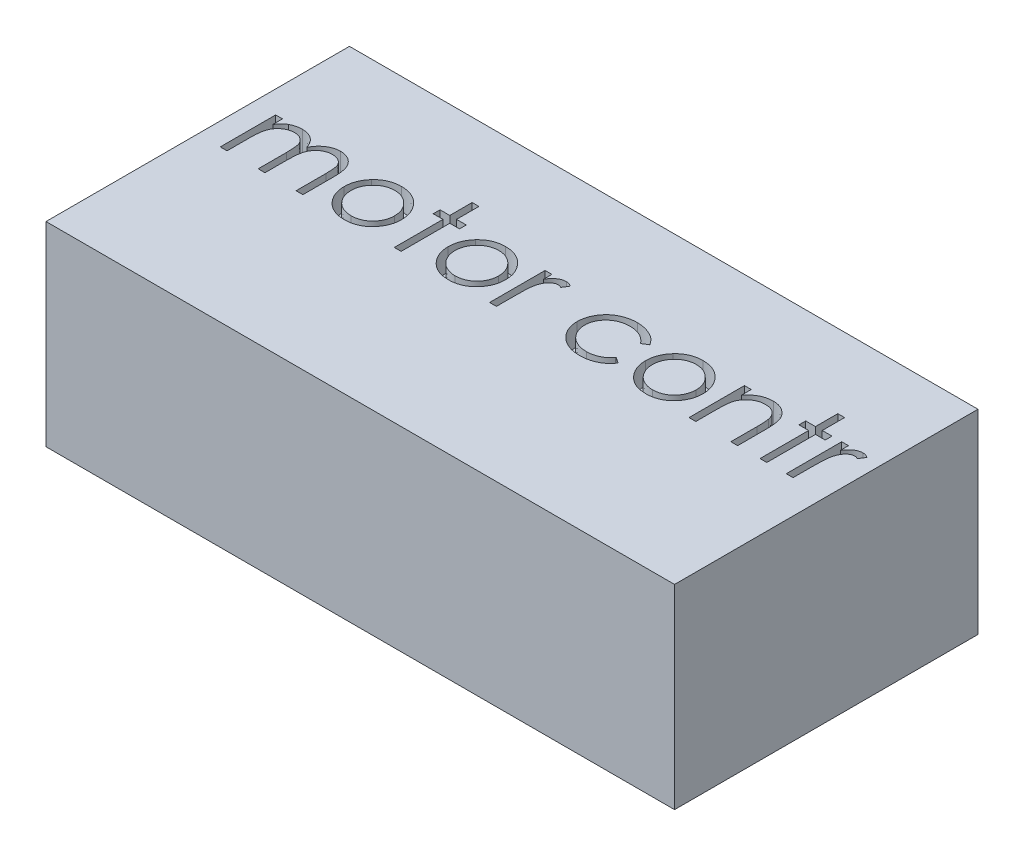
from build123d import *

# Parameters (mm, degrees)
SKETCH1_W           = 29
SKETCH1_H           = 14
BOSS_EXTRUDE1_DEPTH = 9
CUT_EXTRUDE1_DEPTH  = 1


with BuildPart() as part:
    # Sketch1 → Boss-Extrude1 (new body)
    with BuildSketch(Plane(origin=(0, 0, 0), x_dir=(1, 0, 0), z_dir=(0, 1, 0))):
        Rectangle(SKETCH1_W, SKETCH1_H)
    extrude(amount=BOSS_EXTRUDE1_DEPTH)

    # Sketch2 → Cut-Extrude1 (cut)
    with BuildSketch(Plane(origin=(0, 9, 0), x_dir=(1, 0, 0), z_dir=(0, 1, 0))):
        with BuildLine():
            Line((-13.461538462, 2.557692308), (-13.147435897, 2.557692308))
            Line((-13.147435897, 2.557692308), (-13.147435897, 2.11318109))
            add(Edge.make_bspline(
                [(-13.147435897, 2.11318109), (-13.119151948, 2.152068691), (-13.064957188, 2.226581065), (-12.976091535, 2.324771349), (-12.887315423, 2.408099503), (-12.823382041, 2.451842375), (-12.792668269, 2.472856571)],
                knots=[0, 0, 0, 0, 0.000144152, 0.000276209, 0.000396804, 0.000508302, 0.000508302, 0.000508302, 0.000508302], degree=3))
            add(Edge.make_bspline(
                [(-12.792668269, 2.472856571), (-12.750803607, 2.492861936), (-12.667805707, 2.532523149), (-12.536386482, 2.572756708), (-12.401911813, 2.597481809), (-12.311103599, 2.600863183), (-12.265424679, 2.602564103)],
                knots=[0, 0, 0, 0, 0.000139031, 0.000275633, 0.000410962, 0.000547939, 0.000547939, 0.000547939, 0.000547939], degree=3))
            add(Edge.make_bspline(
                [(-12.265424679, 2.602564103), (-12.234531683, 2.601518812), (-12.173396104, 2.599450238), (-12.082812014, 2.585990202), (-11.994953402, 2.562724029), (-11.910339373, 2.530316705), (-11.830618693, 2.491070018), (-11.757529496, 2.445020311), (-11.691905287, 2.393323235), (-11.633779236, 2.333644302), (-11.581510211, 2.264307704), (-11.533431364, 2.183443455), (-11.489006152, 2.089235794), (-11.464384843, 2.020869253), (-11.451422276, 1.984875801)],
                knots=[0, 0, 0, 0, 9.2678e-05, 0.000183405, 0.000274048, 0.000364807, 0.000454797, 0.00054019, 0.000623517, 0.000704829, 0.000789387, 0.000883415, 0.000986597, 0.001101318, 0.001101318, 0.001101318, 0.001101318], degree=3))
            add(Edge.make_bspline(
                [(-11.451422276, 1.984875801), (-11.437711024, 2.009600221), (-11.410729207, 2.058254406), (-11.36542357, 2.127112668), (-11.317955774, 2.19151946), (-11.267921281, 2.251525884), (-11.215496694, 2.306835614), (-11.160435293, 2.357631516), (-11.103050512, 2.40413173), (-11.023258272, 2.458454889), (-10.919445665, 2.516156071), (-10.78855755, 2.566184515), (-10.652407378, 2.597100643), (-10.55998968, 2.600730916), (-10.513321314, 2.602564103)],
                knots=[0, 0, 0, 0, 8.4789e-05, 0.000166854, 0.000247064, 0.000324714, 0.000401089, 0.000475513, 0.000549314, 0.000622436, 0.0007649, 0.000904487, 0.001041601, 0.001181469, 0.001181469, 0.001181469, 0.001181469], degree=3))
            add(Edge.make_bspline(
                [(-10.513321314, 2.602564103), (-10.470439851, 2.600946882), (-10.386516665, 2.597781823), (-10.264339399, 2.57292835), (-10.150397594, 2.530250703), (-10.044920518, 2.472017066), (-9.949760704, 2.398837883), (-9.867044395, 2.311769046), (-9.797274032, 2.211426423), (-9.751695392, 2.117034434), (-9.720780128, 2.033699101), (-9.701718894, 1.96269281), (-9.684879199, 1.884541257), (-9.670897953, 1.799150995), (-9.660679401, 1.706220387), (-9.653108686, 1.605901511), (-9.647984612, 1.498116399), (-9.64762254, 1.423750899), (-9.647435897, 1.385416667)],
                knots=[0, 0, 0, 0, 0.000128581, 0.000251645, 0.00037211, 0.000492305, 0.000611786, 0.000730807, 0.000851198, 0.000976936, 0.001044145, 0.001117629, 0.001197252, 0.00128393, 0.001377074, 0.001477631, 0.001585715, 0.001700707, 0.001700707, 0.001700707, 0.001700707], degree=3))
            Line((-9.647435897, 1.385416667), (-9.647435897, 0))
            Line((-9.647435897, 0), (-9.961538462, 0))
            Line((-9.961538462, 0), (-9.961538462, 1.38681891))
            add(Edge.make_bspline(
                [(-9.961538462, 1.38681891), (-9.961616345, 1.419539484), (-9.961766024, 1.482423451), (-9.964459655, 1.572675902), (-9.969534969, 1.654944259), (-9.975469608, 1.729116348), (-9.983713418, 1.795365136), (-9.994359349, 1.853557555), (-10.005637029, 1.904151366), (-10.02437302, 1.960237414), (-10.054320912, 2.022107624), (-10.099938392, 2.0888312), (-10.157408498, 2.146912), (-10.223768655, 2.197330317), (-10.299317099, 2.238323958), (-10.382581823, 2.267599968), (-10.473045874, 2.285722846), (-10.535668663, 2.287528862), (-10.568008814, 2.288461538)],
                knots=[0, 0, 0, 0, 9.816e-05, 0.000188648, 0.000270826, 0.000345412, 0.000411852, 0.000470988, 0.000522857, 0.0005672, 0.000648106, 0.000728233, 0.000808554, 0.000892128, 0.000977461, 0.001065278, 0.001156029, 0.001252946, 0.001252946, 0.001252946, 0.001252946], degree=3))
            add(Edge.make_bspline(
                [(-10.568008814, 2.288461538), (-10.607678768, 2.287045381), (-10.68608168, 2.284246516), (-10.800527166, 2.255672643), (-10.910498182, 2.212592392), (-11.012713315, 2.150159935), (-11.106741106, 2.075351571), (-11.187640684, 1.986401975), (-11.254472869, 1.885772048), (-11.299726845, 1.792625346), (-11.328316147, 1.708955902), (-11.347193062, 1.63585853), (-11.361876454, 1.552776962), (-11.375646983, 1.460269472), (-11.384634711, 1.357699291), (-11.392803083, 1.24554089), (-11.396623946, 1.123456931), (-11.397158405, 1.038830242), (-11.397435897, 0.994891827)],
                knots=[0, 0, 0, 0, 0.000118788, 0.00023477, 0.000351815, 0.000471937, 0.000592603, 0.000711217, 0.000831002, 0.000953929, 0.001020668, 0.001096002, 0.00118016, 0.001273662, 0.001376495, 0.001488939, 0.001611007, 0.001742825, 0.001742825, 0.001742825, 0.001742825], degree=3))
            Line((-11.397435897, 0.994891827), (-11.397435897, 0))
            Line((-11.397435897, 0), (-11.711538462, 0))
            Line((-11.711538462, 0), (-11.711538462, 1.300580929))
            add(Edge.make_bspline(
                [(-11.711538462, 1.300580929), (-11.711617893, 1.337274248), (-11.71177071, 1.407868505), (-11.714447027, 1.509102181), (-11.719533649, 1.601183261), (-11.725414197, 1.684004725), (-11.733874376, 1.757416053), (-11.743484138, 1.821810811), (-11.754832748, 1.877027563), (-11.773622633, 1.937590947), (-11.802337101, 2.00431187), (-11.848525363, 2.075452892), (-11.906132944, 2.137720989), (-11.973703819, 2.190879738), (-12.049709502, 2.234821219), (-12.133692902, 2.266480971), (-12.224897815, 2.28490526), (-12.287775521, 2.287253757), (-12.320112179, 2.288461538)],
                knots=[0, 0, 0, 0, 0.000110078, 0.00021178, 0.000303758, 0.00038673, 0.000460827, 0.00052538, 0.000582037, 0.000629718, 0.00071543, 0.000799052, 0.000882908, 0.000968755, 0.001056067, 0.001145266, 0.001236843, 0.001333803, 0.001333803, 0.001333803, 0.001333803], degree=3))
            add(Edge.make_bspline(
                [(-12.320112179, 2.288461538), (-12.358128391, 2.286931078), (-12.43389335, 2.283880926), (-12.54519532, 2.256426652), (-12.652681004, 2.213422577), (-12.754635702, 2.153762758), (-12.848309851, 2.07986368), (-12.930318118, 1.992948784), (-12.999260644, 1.89409975), (-13.044992458, 1.801935234), (-13.074490933, 1.720361959), (-13.094086267, 1.651011011), (-13.110925893, 1.574010763), (-13.123439915, 1.489123652), (-13.13552033, 1.396902558), (-13.141350639, 1.296888068), (-13.147022202, 1.18916598), (-13.147294616, 1.114793435), (-13.147435897, 1.076221955)],
                knots=[0, 0, 0, 0, 0.000113893, 0.000226985, 0.000341817, 0.000460265, 0.000580056, 0.000698595, 0.000817435, 0.000940348, 0.001005999, 0.001077458, 0.001156396, 0.001242271, 0.001334801, 0.001435306, 0.00154269, 0.001658383, 0.001658383, 0.001658383, 0.001658383], degree=3))
            Line((-13.147435897, 1.076221955), (-13.147435897, 0))
            Line((-13.147435897, 0), (-13.461538462, 0))
            Line((-13.461538462, 0), (-13.461538462, 2.557692308))
        make_face()
        with BuildLine():
            add(Edge.make_bspline(
                [(-7.694110577, 2.602564103), (-7.646119304, 2.601542211), (-7.552020147, 2.599538533), (-7.414212261, 2.578123567), (-7.282667125, 2.545376203), (-7.156880933, 2.500104641), (-7.038464637, 2.43942269), (-6.925693393, 2.367013399), (-6.818876384, 2.281230805), (-6.754853355, 2.214872737), (-6.722355769, 2.181189904)],
                knots=[0, 0, 0, 0, 0.000143868, 0.000282091, 0.000417278, 0.000550139, 0.000682145, 0.000815559, 0.000951665, 0.001091969, 0.001091969, 0.001091969, 0.001091969], degree=3))
            add(Edge.make_bspline(
                [(-6.722355769, 2.181189904), (-6.694373815, 2.148975918), (-6.638951435, 2.085171376), (-6.567885716, 1.981715763), (-6.506664156, 1.874575662), (-6.457601195, 1.762328336), (-6.418916171, 1.645953664), (-6.391450475, 1.525051653), (-6.37511354, 1.399889306), (-6.372910573, 1.314885468), (-6.371794872, 1.271834936)],
                knots=[0, 0, 0, 0, 0.000127922, 0.000253368, 0.000375813, 0.000497617, 0.000620225, 0.000743195, 0.000869033, 0.000998161, 0.000998161, 0.000998161, 0.000998161], degree=3))
            add(Edge.make_bspline(
                [(-6.371794872, 1.271834936), (-6.372776209, 1.228534878), (-6.374715377, 1.142971945), (-6.393058994, 1.016952579), (-6.42159008, 0.894757756), (-6.462421918, 0.776899063), (-6.514780027, 0.663016235), (-6.578670715, 0.553606686), (-6.654542332, 0.448454553), (-6.740546329, 0.348452714), (-6.835598205, 0.2562865), (-6.938714353, 0.17595823), (-7.047868387, 0.107136706), (-7.16451174, 0.05170029), (-7.287579227, 0.00799059), (-7.417336295, -0.022709427), (-7.553581365, -0.04127111), (-7.646608587, -0.043654684), (-7.694110577, -0.044871795)],
                knots=[0, 0, 0, 0, 0.000129829, 0.000256548, 0.000381202, 0.000505812, 0.000630045, 0.000756669, 0.000885282, 0.001018518, 0.001151902, 0.001281775, 0.001409974, 0.001538236, 0.001668405, 0.001801048, 0.001937587, 0.002080055, 0.002080055, 0.002080055, 0.002080055], degree=3))
            add(Edge.make_bspline(
                [(-7.694110577, -0.044871795), (-7.741845296, -0.043650599), (-7.835336156, -0.041258824), (-7.972062138, -0.022781541), (-8.102051757, 0.007976441), (-8.225280356, 0.051843934), (-8.342425202, 0.107138478), (-8.452211699, 0.175750167), (-8.555411615, 0.256310322), (-8.650483599, 0.348446259), (-8.736482205, 0.448456216), (-8.812355213, 0.553606254), (-8.876245539, 0.663016348), (-8.928603743, 0.776899033), (-8.969435556, 0.894757764), (-8.997966649, 1.016952577), (-9.016310263, 1.142971945), (-9.018249432, 1.228534878), (-9.019230769, 1.271834936)],
                knots=[0, 0, 0, 0, 0.000143168, 0.000280402, 0.000413045, 0.000543214, 0.000672108, 0.000800903, 0.000930775, 0.00106416, 0.001197395, 0.001326009, 0.001452632, 0.001576866, 0.001701476, 0.00182613, 0.001952849, 0.002082678, 0.002082678, 0.002082678, 0.002082678], degree=3))
            add(Edge.make_bspline(
                [(-9.019230769, 1.271834936), (-9.018107459, 1.314651482), (-9.015883497, 1.399420884), (-8.999562988, 1.524347945), (-8.972204432, 1.645045334), (-8.933473035, 1.76097081), (-8.883957845, 1.872726246), (-8.823596557, 1.980131077), (-8.751805924, 2.083118877), (-8.696603973, 2.146840957), (-8.668669872, 2.179086538)],
                knots=[0, 0, 0, 0, 0.000128428, 0.000254265, 0.000377235, 0.000499178, 0.000620341, 0.000743397, 0.000868267, 0.000996189, 0.000996189, 0.000996189, 0.000996189], degree=3))
            add(Edge.make_bspline(
                [(-8.668669872, 2.179086538), (-8.636221281, 2.213061478), (-8.572405417, 2.279879174), (-8.465056689, 2.365411698), (-8.352562868, 2.439327772), (-8.232837942, 2.498803987), (-8.107155084, 2.545642505), (-7.974935841, 2.57820802), (-7.836660326, 2.599461375), (-7.742100705, 2.601519553), (-7.694110577, 2.602564103)],
                knots=[0, 0, 0, 0, 0.000140798, 0.000276904, 0.000410699, 0.000543958, 0.000677061, 0.000812248, 0.000951858, 0.001095726, 0.001095726, 0.001095726, 0.001095726], degree=3))
        make_face()
        with BuildLine():
            add(Edge.make_bspline(
                [(-7.695512821, 2.288461538), (-7.729450432, 2.287496947), (-7.796449561, 2.285592664), (-7.895069145, 2.27110876), (-7.990009299, 2.248161255), (-8.081450143, 2.215557199), (-8.169083316, 2.1734583), (-8.252992718, 2.12174994), (-8.333425158, 2.061116984), (-8.408807221, 1.991654312), (-8.477989534, 1.915775317), (-8.53846751, 1.834926959), (-8.589892616, 1.750420612), (-8.632732775, 1.662168401), (-8.664639964, 1.569275987), (-8.687812986, 1.472795356), (-8.702283226, 1.37252994), (-8.704169605, 1.304368921), (-8.705128205, 1.269731571)],
                knots=[0, 0, 0, 0, 0.000101781, 0.000200935, 0.000298373, 0.000394396, 0.000491609, 0.000589491, 0.000689611, 0.000793323, 0.000896562, 0.000997243, 0.001095722, 0.001192936, 0.001290943, 0.001389744, 0.001490285, 0.001594167, 0.001594167, 0.001594167, 0.001594167], degree=3))
            add(Edge.make_bspline(
                [(-8.705128205, 1.269731571), (-8.703521381, 1.224979543), (-8.700332137, 1.136155138), (-8.674396901, 1.005344015), (-8.631010621, 0.879762163), (-8.572423341, 0.760145777), (-8.499017122, 0.649473499), (-8.412530056, 0.550802015), (-8.313890355, 0.465616203), (-8.204273855, 0.394935358), (-8.085919537, 0.338775602), (-7.960663216, 0.298976626), (-7.830022522, 0.273104934), (-7.740741791, 0.270533459), (-7.695512821, 0.269230769)],
                knots=[0, 0, 0, 0, 0.000134178, 0.000266319, 0.000398243, 0.00053182, 0.000664828, 0.000795487, 0.000924236, 0.001054533, 0.001185628, 0.001316003, 0.001448011, 0.001583547, 0.001583547, 0.001583547, 0.001583547], degree=3))
            add(Edge.make_bspline(
                [(-7.695512821, 0.269230769), (-7.650286452, 0.270541049), (-7.561010856, 0.273127506), (-7.430551679, 0.298846326), (-7.305637707, 0.338949987), (-7.187406319, 0.394872197), (-7.077839716, 0.465884611), (-6.978490595, 0.550320988), (-6.892741983, 0.64973484), (-6.819408379, 0.760292369), (-6.759861636, 0.879576721), (-6.716678434, 1.005367193), (-6.690680848, 1.136149235), (-6.687500019, 1.224977566), (-6.685897436, 1.269731571)],
                knots=[0, 0, 0, 0, 0.000135536, 0.000267545, 0.000397252, 0.000528347, 0.000658644, 0.000787925, 0.000918122, 0.00105113, 0.001185017, 0.001316942, 0.001449082, 0.00158326, 0.00158326, 0.00158326, 0.00158326], degree=3))
            add(Edge.make_bspline(
                [(-6.685897436, 1.269731571), (-6.686855706, 1.304369128), (-6.688741435, 1.372530554), (-6.703216399, 1.472793007), (-6.726371939, 1.569284604), (-6.758343556, 1.662136607), (-6.80099757, 1.750649112), (-6.853414363, 1.834678839), (-6.913645389, 1.916055385), (-6.98366251, 1.991409026), (-7.058965887, 2.061144062), (-7.139430926, 2.121773452), (-7.223215904, 2.173231047), (-7.310594487, 2.215917288), (-7.402047055, 2.247864628), (-7.496854184, 2.271241259), (-7.595052994, 2.285531456), (-7.661812037, 2.287478598), (-7.695512821, 2.288461538)],
                knots=[0, 0, 0, 0, 0.000103882, 0.000204424, 0.000303225, 0.000401232, 0.000498445, 0.000597291, 0.000697972, 0.000801684, 0.000905395, 0.001005516, 0.001103397, 0.001199979, 0.001296663, 0.00139342, 0.001492573, 0.001593654, 0.001593654, 0.001593654, 0.001593654], degree=3))
        make_face(mode=Mode.SUBTRACT)
        Polygon((-5.429487179, 3.58974359), (-5.115384615, 3.58974359), (-5.115384615, 2.557692308), (-4.666666667, 2.557692308), (-4.666666667, 2.243589744), (-5.115384615, 2.243589744), (-5.115384615, 0), (-5.429487179, 0), (-5.429487179, 2.243589744), (-5.878205128, 2.243589744), (-5.878205128, 2.557692308), (-5.429487179, 2.557692308), align=None)
        with BuildLine():
            add(Edge.make_bspline(
                [(-2.892828526, 2.602564103), (-2.844837253, 2.601542211), (-2.750738095, 2.599538533), (-2.612930209, 2.578123567), (-2.481385073, 2.545376203), (-2.355598881, 2.500104641), (-2.237182586, 2.43942269), (-2.124411342, 2.367013399), (-2.017594333, 2.281230805), (-1.953571304, 2.214872737), (-1.921073718, 2.181189904)],
                knots=[0, 0, 0, 0, 0.000143868, 0.000282091, 0.000417278, 0.000550139, 0.000682145, 0.000815559, 0.000951665, 0.001091969, 0.001091969, 0.001091969, 0.001091969], degree=3))
            add(Edge.make_bspline(
                [(-1.921073718, 2.181189904), (-1.893091764, 2.148975918), (-1.837669384, 2.085171376), (-1.766603665, 1.981715763), (-1.705382105, 1.874575662), (-1.656319144, 1.762328336), (-1.61763412, 1.645953664), (-1.590168424, 1.525051653), (-1.573831489, 1.399889306), (-1.571628522, 1.314885468), (-1.570512821, 1.271834936)],
                knots=[0, 0, 0, 0, 0.000127922, 0.000253368, 0.000375813, 0.000497617, 0.000620225, 0.000743195, 0.000869033, 0.000998161, 0.000998161, 0.000998161, 0.000998161], degree=3))
            add(Edge.make_bspline(
                [(-1.570512821, 1.271834936), (-1.571494158, 1.228534878), (-1.573433326, 1.142971945), (-1.591776943, 1.016952579), (-1.620308028, 0.894757756), (-1.661139867, 0.776899063), (-1.713497976, 0.663016235), (-1.777388663, 0.553606686), (-1.853260281, 0.448454553), (-1.939264277, 0.348452714), (-2.034316153, 0.2562865), (-2.137432302, 0.17595823), (-2.246586336, 0.107136706), (-2.363229689, 0.05170029), (-2.486297176, 0.00799059), (-2.616054244, -0.022709427), (-2.752299314, -0.04127111), (-2.845326535, -0.043654684), (-2.892828526, -0.044871795)],
                knots=[0, 0, 0, 0, 0.000129829, 0.000256548, 0.000381202, 0.000505812, 0.000630045, 0.000756669, 0.000885282, 0.001018518, 0.001151902, 0.001281775, 0.001409974, 0.001538236, 0.001668405, 0.001801048, 0.001937587, 0.002080055, 0.002080055, 0.002080055, 0.002080055], degree=3))
            add(Edge.make_bspline(
                [(-2.892828526, -0.044871795), (-2.940563245, -0.043650599), (-3.034054105, -0.041258824), (-3.170780087, -0.022781541), (-3.300769706, 0.007976441), (-3.423998304, 0.051843934), (-3.541143151, 0.107138478), (-3.650929648, 0.175750167), (-3.754129564, 0.256310322), (-3.849201548, 0.348446259), (-3.935200153, 0.448456216), (-4.011073162, 0.553606254), (-4.074963488, 0.663016348), (-4.127321692, 0.776899033), (-4.168153505, 0.894757764), (-4.196684597, 1.016952577), (-4.215028212, 1.142971945), (-4.216967381, 1.228534878), (-4.217948718, 1.271834936)],
                knots=[0, 0, 0, 0, 0.000143168, 0.000280402, 0.000413045, 0.000543214, 0.000672108, 0.000800903, 0.000930775, 0.00106416, 0.001197395, 0.001326009, 0.001452632, 0.001576866, 0.001701476, 0.00182613, 0.001952849, 0.002082678, 0.002082678, 0.002082678, 0.002082678], degree=3))
            add(Edge.make_bspline(
                [(-4.217948718, 1.271834936), (-4.216825408, 1.314651482), (-4.214601446, 1.399420884), (-4.198280937, 1.524347945), (-4.170922381, 1.645045334), (-4.132190984, 1.76097081), (-4.082675793, 1.872726246), (-4.022314505, 1.980131077), (-3.950523873, 2.083118877), (-3.895321921, 2.146840957), (-3.867387821, 2.179086538)],
                knots=[0, 0, 0, 0, 0.000128428, 0.000254265, 0.000377235, 0.000499178, 0.000620341, 0.000743397, 0.000868267, 0.000996189, 0.000996189, 0.000996189, 0.000996189], degree=3))
            add(Edge.make_bspline(
                [(-3.867387821, 2.179086538), (-3.834939229, 2.213061478), (-3.771123366, 2.279879174), (-3.663774638, 2.365411698), (-3.551280817, 2.439327772), (-3.431555891, 2.498803987), (-3.305873033, 2.545642505), (-3.17365379, 2.57820802), (-3.035378275, 2.599461375), (-2.940818654, 2.601519553), (-2.892828526, 2.602564103)],
                knots=[0, 0, 0, 0, 0.000140798, 0.000276904, 0.000410699, 0.000543958, 0.000677061, 0.000812248, 0.000951858, 0.001095726, 0.001095726, 0.001095726, 0.001095726], degree=3))
        make_face()
        with BuildLine():
            add(Edge.make_bspline(
                [(-2.894230769, 2.288461538), (-2.928168381, 2.287496947), (-2.995167509, 2.285592664), (-3.093787094, 2.27110876), (-3.188727248, 2.248161255), (-3.280168092, 2.215557199), (-3.367801264, 2.1734583), (-3.451710667, 2.12174994), (-3.532143107, 2.061116984), (-3.60752517, 1.991654312), (-3.676707482, 1.915775317), (-3.737185459, 1.834926959), (-3.788610565, 1.750420612), (-3.831450724, 1.662168401), (-3.863357912, 1.569275987), (-3.886530935, 1.472795356), (-3.901001175, 1.37252994), (-3.902887554, 1.304368921), (-3.903846154, 1.269731571)],
                knots=[0, 0, 0, 0, 0.000101781, 0.000200935, 0.000298373, 0.000394396, 0.000491609, 0.000589491, 0.000689611, 0.000793323, 0.000896562, 0.000997243, 0.001095722, 0.001192936, 0.001290943, 0.001389744, 0.001490285, 0.001594167, 0.001594167, 0.001594167, 0.001594167], degree=3))
            add(Edge.make_bspline(
                [(-3.903846154, 1.269731571), (-3.90223933, 1.224979543), (-3.899050086, 1.136155138), (-3.873114849, 1.005344015), (-3.829728569, 0.879762163), (-3.77114129, 0.760145777), (-3.697735071, 0.649473499), (-3.611248004, 0.550802015), (-3.512608304, 0.465616203), (-3.402991804, 0.394935358), (-3.284637486, 0.338775602), (-3.159381165, 0.298976626), (-3.028740471, 0.273104934), (-2.93945974, 0.270533459), (-2.894230769, 0.269230769)],
                knots=[0, 0, 0, 0, 0.000134178, 0.000266319, 0.000398243, 0.00053182, 0.000664828, 0.000795487, 0.000924236, 0.001054533, 0.001185628, 0.001316003, 0.001448011, 0.001583547, 0.001583547, 0.001583547, 0.001583547], degree=3))
            add(Edge.make_bspline(
                [(-2.894230769, 0.269230769), (-2.8490044, 0.270541049), (-2.759728804, 0.273127506), (-2.629269627, 0.298846326), (-2.504355656, 0.338949987), (-2.386124268, 0.394872197), (-2.276557665, 0.465884611), (-2.177208543, 0.550320988), (-2.091459932, 0.64973484), (-2.018126327, 0.760292369), (-1.958579585, 0.879576721), (-1.915396383, 1.005367193), (-1.889398797, 1.136149235), (-1.886217968, 1.224977566), (-1.884615385, 1.269731571)],
                knots=[0, 0, 0, 0, 0.000135536, 0.000267545, 0.000397252, 0.000528347, 0.000658644, 0.000787925, 0.000918122, 0.00105113, 0.001185017, 0.001316942, 0.001449082, 0.00158326, 0.00158326, 0.00158326, 0.00158326], degree=3))
            add(Edge.make_bspline(
                [(-1.884615385, 1.269731571), (-1.885573655, 1.304369128), (-1.887459384, 1.372530554), (-1.901934348, 1.472793007), (-1.925089888, 1.569284604), (-1.957061505, 1.662136607), (-1.999715519, 1.750649112), (-2.052132312, 1.834678839), (-2.112363337, 1.916055385), (-2.182380458, 1.991409026), (-2.257683836, 2.061144062), (-2.338148874, 2.121773452), (-2.421933853, 2.173231047), (-2.509312436, 2.215917288), (-2.600765003, 2.247864628), (-2.695572132, 2.271241259), (-2.793770942, 2.285531456), (-2.860529986, 2.287478598), (-2.894230769, 2.288461538)],
                knots=[0, 0, 0, 0, 0.000103882, 0.000204424, 0.000303225, 0.000401232, 0.000498445, 0.000597291, 0.000697972, 0.000801684, 0.000905395, 0.001005516, 0.001103397, 0.001199979, 0.001296663, 0.00139342, 0.001492573, 0.001593654, 0.001593654, 0.001593654, 0.001593654], degree=3))
        make_face(mode=Mode.SUBTRACT)
        with BuildLine():
            Line((-1.032051282, 2.557692308), (-0.717948718, 2.557692308))
            Line((-0.717948718, 2.557692308), (-0.717948718, 2.181189904))
            add(Edge.make_bspline(
                [(-0.717948718, 2.181189904), (-0.694759959, 2.216245732), (-0.650411638, 2.283289731), (-0.576698709, 2.371959032), (-0.501195378, 2.445374079), (-0.42354019, 2.503877598), (-0.34316209, 2.547690717), (-0.261825139, 2.579783752), (-0.178249669, 2.598761067), (-0.122087745, 2.601294726), (-0.093950321, 2.602564103)],
                knots=[0, 0, 0, 0, 0.000126023, 0.000241017, 0.000345147, 0.000441342, 0.00053171, 0.000618946, 0.000702978, 0.000787349, 0.000787349, 0.000787349, 0.000787349], degree=3))
            add(Edge.make_bspline(
                [(-0.093950321, 2.602564103), (-0.072123994, 2.601373576), (-0.027214909, 2.59892399), (0.040767681, 2.581713165), (0.110811133, 2.554235143), (0.15595352, 2.52839492), (0.179487179, 2.514923878)],
                knots=[0, 0, 0, 0, 6.5445e-05, 0.000134658, 0.00020926, 0.000290509, 0.000290509, 0.000290509, 0.000290509], degree=3))
            Line((0.179487179, 2.514923878), (0.007011218, 2.242888622))
            add(Edge.make_bspline(
                [(0.007011218, 2.242888622), (-0.008097803, 2.249628888), (-0.036777618, 2.262423203), (-0.078732184, 2.277565213), (-0.117413521, 2.286481129), (-0.142057079, 2.287831847), (-0.153545673, 2.288461538)],
                knots=[0, 0, 0, 0, 4.9621e-05, 9.4191e-05, 0.00013366, 0.000168129, 0.000168129, 0.000168129, 0.000168129], degree=3))
            add(Edge.make_bspline(
                [(-0.153545673, 2.288461538), (-0.178751407, 2.286781501), (-0.230163797, 2.283354712), (-0.305648296, 2.256415904), (-0.378895501, 2.212890664), (-0.437067164, 2.164619552), (-0.482109417, 2.118071755), (-0.514249642, 2.077423352), (-0.543732389, 2.031844721), (-0.57190261, 1.982115037), (-0.597568904, 1.927385191), (-0.621523573, 1.868201977), (-0.643182436, 1.804496849), (-0.65553268, 1.760114328), (-0.661858974, 1.737379808)],
                knots=[0, 0, 0, 0, 7.549e-05, 0.000153978, 0.000237553, 0.000330197, 0.000379784, 0.000431685, 0.000485357, 0.000542493, 0.000603021, 0.000666557, 0.00073396, 0.000804745, 0.000804745, 0.000804745, 0.000804745], degree=3))
            add(Edge.make_bspline(
                [(-0.661858974, 1.737379808), (-0.666591368, 1.717102634), (-0.677073259, 1.672190235), (-0.687264797, 1.596841711), (-0.697334315, 1.507818052), (-0.704430934, 1.404871459), (-0.711008976, 1.288259015), (-0.714719058, 1.15780307), (-0.717822199, 1.013369718), (-0.717905265, 0.912395365), (-0.717948718, 0.859575321)],
                knots=[0, 0, 0, 0, 6.2435e-05, 0.000138289, 0.000227871, 0.000331224, 0.000447781, 0.000578258, 0.000722716, 0.000881171, 0.000881171, 0.000881171, 0.000881171], degree=3))
            Line((-0.717948718, 0.859575321), (-0.717948718, 0))
            Line((-0.717948718, 0), (-1.032051282, 0))
            Line((-1.032051282, 0), (-1.032051282, 2.557692308))
        make_face()
        with BuildLine():
            Line((4.352564103, 2.003104968), (4.089643429, 1.83974359))
            add(Edge.make_bspline(
                [(4.089643429, 1.83974359), (4.060813564, 1.875571984), (4.004066869, 1.946094094), (3.905527633, 2.037104027), (3.800516218, 2.115271069), (3.687238171, 2.17897482), (3.565852371, 2.22819627), (3.436837519, 2.263026476), (3.300212014, 2.284730719), (3.206546815, 2.287197555), (3.158553686, 2.288461538)],
                knots=[0, 0, 0, 0, 0.0001378, 0.000271237, 0.000401088, 0.000529797, 0.000659994, 0.000793002, 0.000929944, 0.001073845, 0.001073845, 0.001073845, 0.001073845], degree=3))
            add(Edge.make_bspline(
                [(3.158553686, 2.288461538), (3.120194729, 2.287404696), (3.044647806, 2.285323274), (2.933741653, 2.272312781), (2.8280993, 2.248670773), (2.727058591, 2.217519816), (2.631338172, 2.175769526), (2.540687254, 2.12495977), (2.454301764, 2.06590973), (2.374685023, 1.997499184), (2.301856015, 1.923100516), (2.238757101, 1.843346821), (2.183820168, 1.76062693), (2.140714212, 1.672875188), (2.105439041, 1.582099134), (2.082232321, 1.486585279), (2.066767626, 1.387557271), (2.064998297, 1.320038931), (2.064102564, 1.285857372)],
                knots=[0, 0, 0, 0, 0.000115089, 0.000226664, 0.000334347, 0.000439455, 0.000543394, 0.000646972, 0.000750824, 0.000856758, 0.000961376, 0.00106266, 0.001161449, 0.00125865, 0.001355399, 0.001453007, 0.001552955, 0.001655437, 0.001655437, 0.001655437, 0.001655437], degree=3))
            add(Edge.make_bspline(
                [(2.064102564, 1.285857372), (2.065881816, 1.241088161), (2.069416347, 1.152152965), (2.097117807, 1.020874863), (2.142462214, 0.893951173), (2.204520065, 0.772283036), (2.282997199, 0.65968888), (2.375169762, 0.558705426), (2.481088846, 0.471289398), (2.599821176, 0.398816873), (2.72857892, 0.340555505), (2.865969024, 0.299048172), (3.010868805, 0.2739958), (3.110075552, 0.270839857), (3.160657051, 0.269230769)],
                knots=[0, 0, 0, 0, 0.000134224, 0.00026664, 0.000400581, 0.000537609, 0.000675117, 0.000811087, 0.000946551, 0.001085679, 0.001227203, 0.001369372, 0.001515181, 0.001666857, 0.001666857, 0.001666857, 0.001666857], degree=3))
            add(Edge.make_bspline(
                [(3.160657051, 0.269230769), (3.207012236, 0.270530266), (3.298112474, 0.273084123), (3.431279759, 0.294613087), (3.55805967, 0.32985672), (3.678447701, 0.37900437), (3.792223867, 0.442531886), (3.898653042, 0.520891057), (3.99985298, 0.611827657), (4.059349956, 0.682145629), (4.089643429, 0.717948718)],
                knots=[0, 0, 0, 0, 0.000138999, 0.00027317, 0.000403475, 0.000533023, 0.000662344, 0.000793326, 0.000928824, 0.001069379, 0.001069379, 0.001069379, 0.001069379], degree=3))
            Line((4.089643429, 0.717948718), (4.352564103, 0.545472756))
            add(Edge.make_bspline(
                [(4.352564103, 0.545472756), (4.3369764, 0.522582029), (4.305852733, 0.476876553), (4.253825108, 0.412432436), (4.197705276, 0.352110754), (4.137712179, 0.295992364), (4.07462917, 0.242734345), (4.00630126, 0.19488277), (3.934931649, 0.149747947), (3.859682491, 0.109135075), (3.781331793, 0.072628754), (3.699989803, 0.041237583), (3.61600999, 0.014267477), (3.529293614, -0.00716987), (3.439669716, -0.024280708), (3.347370082, -0.03563441), (3.2524265, -0.044109691), (3.188254349, -0.044615558), (3.155749199, -0.044871795)],
                knots=[0, 0, 0, 0, 8.3056e-05, 0.000165835, 0.000248187, 0.000330026, 0.000412165, 0.000495625, 0.000580051, 0.000665384, 0.00075196, 0.000839196, 0.00092678, 0.001016395, 0.001107013, 0.001200326, 0.001295291, 0.001392769, 0.001392769, 0.001392769, 0.001392769], degree=3))
            add(Edge.make_bspline(
                [(3.155749199, -0.044871795), (3.106138315, -0.043980515), (3.008900623, -0.0422336), (2.866578115, -0.023025125), (2.730564448, 0.005932491), (2.60090609, 0.047496225), (2.477582856, 0.101001001), (2.360709738, 0.166357915), (2.250673719, 0.244109705), (2.148562937, 0.332872475), (2.054781491, 0.429113115), (1.9742553, 0.532963033), (1.90441003, 0.640604081), (1.848322487, 0.754413607), (1.80367556, 0.87287898), (1.773170727, 0.99694922), (1.75344099, 1.125601474), (1.75115761, 1.213334356), (1.75, 1.2578125)],
                knots=[0, 0, 0, 0, 0.000148744, 0.000291539, 0.000430022, 0.000565498, 0.000699266, 0.000832672, 0.000966504, 0.001102706, 0.001238073, 0.00136893, 0.00149632, 0.001622368, 0.001748823, 0.001875338, 0.002005032, 0.002138395, 0.002138395, 0.002138395, 0.002138395], degree=3))
            add(Edge.make_bspline(
                [(1.75, 1.2578125), (1.750441016, 1.287990935), (1.75131827, 1.348020822), (1.761380198, 1.437115889), (1.774378671, 1.525024434), (1.796404408, 1.610632153), (1.821845039, 1.695237443), (1.854320571, 1.777820545), (1.892415966, 1.858765217), (1.935667913, 1.937862947), (1.984356659, 2.013812487), (2.038237892, 2.085566151), (2.095282228, 2.153985917), (2.15815834, 2.216709677), (2.224197994, 2.276245869), (2.29526957, 2.331003993), (2.370965421, 2.381144984), (2.450148744, 2.427595999), (2.532773455, 2.468955434), (2.618340126, 2.504588672), (2.706333155, 2.535041248), (2.796893299, 2.559150167), (2.889419472, 2.579367591), (2.98464081, 2.592085437), (3.082193032, 2.60107171), (3.148249055, 2.602062502), (3.181690705, 2.602564103)],
                knots=[0, 0, 0, 0, 9.0488e-05, 0.000179996, 0.000268751, 0.000356836, 0.000444879, 0.000533675, 0.000622751, 0.00071312, 0.000803944, 0.000893127, 0.000982181, 0.001070925, 0.00115931, 0.001248782, 0.001339788, 0.001431538, 0.001524036, 0.001616746, 0.001709427, 0.001803141, 0.001897749, 0.001993333, 0.002091151, 0.002191451, 0.002191451, 0.002191451, 0.002191451], degree=3))
            add(Edge.make_bspline(
                [(3.181690705, 2.602564103), (3.223570813, 2.601642212), (3.307121693, 2.599803037), (3.431062399, 2.584324385), (3.553177593, 2.560987969), (3.671324697, 2.526415139), (3.784071211, 2.484551483), (3.889606661, 2.437538769), (3.985446765, 2.382944165), (4.073374354, 2.323224051), (4.153553872, 2.255863145), (4.226808364, 2.180056188), (4.294640014, 2.096197709), (4.333096725, 2.034391978), (4.352564103, 2.003104968)],
                knots=[0, 0, 0, 0, 0.000125597, 0.000250566, 0.00037418, 0.000498223, 0.000619345, 0.000734815, 0.00084439, 0.000949794, 0.001053299, 0.001157917, 0.001265662, 0.001376119, 0.001376119, 0.001376119, 0.001376119], degree=3))
        make_face()
        with BuildLine():
            add(Edge.make_bspline(
                [(6.216145833, 2.602564103), (6.264137106, 2.601542211), (6.358236264, 2.599538533), (6.49604415, 2.578123567), (6.627589286, 2.545376203), (6.753375478, 2.500104641), (6.871791773, 2.43942269), (6.984563017, 2.367013399), (7.091380026, 2.281230805), (7.155403055, 2.214872737), (7.187900641, 2.181189904)],
                knots=[0, 0, 0, 0, 0.000143868, 0.000282091, 0.000417278, 0.000550139, 0.000682145, 0.000815559, 0.000951665, 0.001091969, 0.001091969, 0.001091969, 0.001091969], degree=3))
            add(Edge.make_bspline(
                [(7.187900641, 2.181189904), (7.215882595, 2.148975918), (7.271304975, 2.085171376), (7.342370694, 1.981715763), (7.403592254, 1.874575662), (7.452655215, 1.762328336), (7.491340239, 1.645953664), (7.518805935, 1.525051653), (7.53514287, 1.399889306), (7.537345837, 1.314885468), (7.538461538, 1.271834936)],
                knots=[0, 0, 0, 0, 0.000127922, 0.000253368, 0.000375813, 0.000497617, 0.000620225, 0.000743195, 0.000869033, 0.000998161, 0.000998161, 0.000998161, 0.000998161], degree=3))
            add(Edge.make_bspline(
                [(7.538461538, 1.271834936), (7.537480201, 1.228534878), (7.535541033, 1.142971945), (7.517197416, 1.016952579), (7.488666331, 0.894757756), (7.447834492, 0.776899063), (7.395476383, 0.663016235), (7.331585696, 0.553606686), (7.255714078, 0.448454553), (7.169710082, 0.348452714), (7.074658206, 0.2562865), (6.971542057, 0.17595823), (6.862388023, 0.107136706), (6.74574467, 0.05170029), (6.622677183, 0.00799059), (6.492920115, -0.022709427), (6.356675045, -0.04127111), (6.263647824, -0.043654684), (6.216145833, -0.044871795)],
                knots=[0, 0, 0, 0, 0.000129829, 0.000256548, 0.000381202, 0.000505812, 0.000630045, 0.000756669, 0.000885282, 0.001018518, 0.001151902, 0.001281775, 0.001409974, 0.001538236, 0.001668405, 0.001801048, 0.001937587, 0.002080055, 0.002080055, 0.002080055, 0.002080055], degree=3))
            add(Edge.make_bspline(
                [(6.216145833, -0.044871795), (6.168411114, -0.043650599), (6.074920254, -0.041258824), (5.938194272, -0.022781541), (5.808204653, 0.007976441), (5.684976055, 0.051843934), (5.567831208, 0.107138478), (5.458044711, 0.175750167), (5.354844795, 0.256310322), (5.259772811, 0.348446259), (5.173774206, 0.448456216), (5.097901197, 0.553606254), (5.034010871, 0.663016348), (4.981652667, 0.776899033), (4.940820854, 0.894757764), (4.912289762, 1.016952577), (4.893946147, 1.142971945), (4.892006978, 1.228534878), (4.891025641, 1.271834936)],
                knots=[0, 0, 0, 0, 0.000143168, 0.000280402, 0.000413045, 0.000543214, 0.000672108, 0.000800903, 0.000930775, 0.00106416, 0.001197395, 0.001326009, 0.001452632, 0.001576866, 0.001701476, 0.00182613, 0.001952849, 0.002082678, 0.002082678, 0.002082678, 0.002082678], degree=3))
            add(Edge.make_bspline(
                [(4.891025641, 1.271834936), (4.892148951, 1.314651482), (4.894372913, 1.399420884), (4.910693422, 1.524347945), (4.938051978, 1.645045334), (4.976783375, 1.76097081), (5.026298566, 1.872726246), (5.086659854, 1.980131077), (5.158450486, 2.083118877), (5.213652438, 2.146840957), (5.241586538, 2.179086538)],
                knots=[0, 0, 0, 0, 0.000128428, 0.000254265, 0.000377235, 0.000499178, 0.000620341, 0.000743397, 0.000868267, 0.000996189, 0.000996189, 0.000996189, 0.000996189], degree=3))
            add(Edge.make_bspline(
                [(5.241586538, 2.179086538), (5.274035129, 2.213061478), (5.337850993, 2.279879174), (5.445199721, 2.365411698), (5.557693542, 2.439327772), (5.677418468, 2.498803987), (5.803101326, 2.545642505), (5.935320569, 2.57820802), (6.073596084, 2.599461375), (6.168155705, 2.601519553), (6.216145833, 2.602564103)],
                knots=[0, 0, 0, 0, 0.000140798, 0.000276904, 0.000410699, 0.000543958, 0.000677061, 0.000812248, 0.000951858, 0.001095726, 0.001095726, 0.001095726, 0.001095726], degree=3))
        make_face()
        with BuildLine():
            add(Edge.make_bspline(
                [(6.21474359, 2.288461538), (6.180805978, 2.287496947), (6.11380685, 2.285592664), (6.015187265, 2.27110876), (5.920247111, 2.248161255), (5.828806267, 2.215557199), (5.741173095, 2.1734583), (5.657263692, 2.12174994), (5.576831252, 2.061116984), (5.501449189, 1.991654312), (5.432266877, 1.915775317), (5.3717889, 1.834926959), (5.320363794, 1.750420612), (5.277523635, 1.662168401), (5.245616447, 1.569275987), (5.222443424, 1.472795356), (5.207973184, 1.37252994), (5.206086805, 1.304368921), (5.205128205, 1.269731571)],
                knots=[0, 0, 0, 0, 0.000101781, 0.000200935, 0.000298373, 0.000394396, 0.000491609, 0.000589491, 0.000689611, 0.000793323, 0.000896562, 0.000997243, 0.001095722, 0.001192936, 0.001290943, 0.001389744, 0.001490285, 0.001594167, 0.001594167, 0.001594167, 0.001594167], degree=3))
            add(Edge.make_bspline(
                [(5.205128205, 1.269731571), (5.206735029, 1.224979543), (5.209924273, 1.136155138), (5.23585951, 1.005344015), (5.27924579, 0.879762163), (5.337833069, 0.760145777), (5.411239288, 0.649473499), (5.497726355, 0.550802015), (5.596366055, 0.465616203), (5.705982555, 0.394935358), (5.824336873, 0.338775602), (5.949593194, 0.298976626), (6.080233888, 0.273104934), (6.169514619, 0.270533459), (6.21474359, 0.269230769)],
                knots=[0, 0, 0, 0, 0.000134178, 0.000266319, 0.000398243, 0.00053182, 0.000664828, 0.000795487, 0.000924236, 0.001054533, 0.001185628, 0.001316003, 0.001448011, 0.001583547, 0.001583547, 0.001583547, 0.001583547], degree=3))
            add(Edge.make_bspline(
                [(6.21474359, 0.269230769), (6.259969959, 0.270541049), (6.349245555, 0.273127506), (6.479704731, 0.298846326), (6.604618703, 0.338949987), (6.722850091, 0.394872197), (6.832416694, 0.465884611), (6.931765816, 0.550320988), (7.017514427, 0.64973484), (7.090848032, 0.760292369), (7.150394774, 0.879576721), (7.193577976, 1.005367193), (7.219575562, 1.136149235), (7.222756391, 1.224977566), (7.224358974, 1.269731571)],
                knots=[0, 0, 0, 0, 0.000135536, 0.000267545, 0.000397252, 0.000528347, 0.000658644, 0.000787925, 0.000918122, 0.00105113, 0.001185017, 0.001316942, 0.001449082, 0.00158326, 0.00158326, 0.00158326, 0.00158326], degree=3))
            add(Edge.make_bspline(
                [(7.224358974, 1.269731571), (7.223400704, 1.304369128), (7.221514975, 1.372530554), (7.207040011, 1.472793007), (7.183884471, 1.569284604), (7.151912854, 1.662136607), (7.10925884, 1.750649112), (7.056842047, 1.834678839), (6.996611022, 1.916055385), (6.926593901, 1.991409026), (6.851290523, 2.061144062), (6.770825485, 2.121773452), (6.687040506, 2.173231047), (6.599661923, 2.215917288), (6.508209356, 2.247864628), (6.413402227, 2.271241259), (6.315203417, 2.285531456), (6.248444373, 2.287478598), (6.21474359, 2.288461538)],
                knots=[0, 0, 0, 0, 0.000103882, 0.000204424, 0.000303225, 0.000401232, 0.000498445, 0.000597291, 0.000697972, 0.000801684, 0.000905395, 0.001005516, 0.001103397, 0.001199979, 0.001296663, 0.00139342, 0.001492573, 0.001593654, 0.001593654, 0.001593654, 0.001593654], degree=3))
        make_face(mode=Mode.SUBTRACT)
        with BuildLine():
            Line((8.166666667, 2.557692308), (8.480769231, 2.557692308))
            Line((8.480769231, 2.557692308), (8.480769231, 2.096354167))
            add(Edge.make_bspline(
                [(8.480769231, 2.096354167), (8.514306866, 2.13819689), (8.579387817, 2.219394153), (8.68777215, 2.326114728), (8.802316051, 2.414059953), (8.922318054, 2.484163747), (9.047941064, 2.537010373), (9.178419334, 2.575176304), (9.31453404, 2.598061132), (9.407098477, 2.601051363), (9.453926282, 2.602564103)],
                knots=[0, 0, 0, 0, 0.000160777, 0.000311994, 0.000455029, 0.000592958, 0.000727738, 0.000862858, 0.001000022, 0.001140458, 0.001140458, 0.001140458, 0.001140458], degree=3))
            add(Edge.make_bspline(
                [(9.453926282, 2.602564103), (9.501256916, 2.600818907), (9.593894384, 2.597403139), (9.728772445, 2.570386448), (9.854745839, 2.524241192), (9.971365395, 2.461029122), (10.076492608, 2.382422649), (10.16881746, 2.290844867), (10.245180707, 2.185508784), (10.29637807, 2.087785627), (10.330103718, 2.001096833), (10.351336055, 1.926850083), (10.369367037, 1.844131932), (10.384998785, 1.753192343), (10.395575897, 1.653394153), (10.403918188, 1.545146461), (10.409896882, 1.42848433), (10.410134089, 1.347797703), (10.41025641, 1.306189904)],
                knots=[0, 0, 0, 0, 0.00014192, 0.000277771, 0.000410631, 0.000543023, 0.000674273, 0.000803173, 0.000931629, 0.001063031, 0.00113295, 0.001210382, 0.001294414, 0.001386856, 0.001487045, 0.001595345, 0.001712567, 0.001837375, 0.001837375, 0.001837375, 0.001837375], degree=3))
            Line((10.41025641, 1.306189904), (10.41025641, 0))
            Line((10.41025641, 0), (10.096153846, 0))
            Line((10.096153846, 0), (10.096153846, 1.203125))
            add(Edge.make_bspline(
                [(10.096153846, 1.203125), (10.095960638, 1.237947445), (10.095591064, 1.304556856), (10.094425417, 1.399925879), (10.091615611, 1.486412457), (10.087667298, 1.563809825), (10.081888267, 1.632043661), (10.075865636, 1.691252938), (10.068500659, 1.74136248), (10.061937746, 1.771527563), (10.058994391, 1.78505609)],
                knots=[0, 0, 0, 0, 0.00010447, 0.000199832, 0.000286116, 0.000364054, 0.000432294, 0.000491525, 0.000542592, 0.000584118, 0.000584118, 0.000584118, 0.000584118], degree=3))
            add(Edge.make_bspline(
                [(10.058994391, 1.78505609), (10.04836886, 1.824767275), (10.027917999, 1.901199019), (9.977384016, 2.004873372), (9.913569835, 2.09307156), (9.835671986, 2.165248281), (9.74444291, 2.221419118), (9.640135767, 2.260393073), (9.523757126, 2.284769342), (9.441902744, 2.287196474), (9.399238782, 2.288461538)],
                knots=[0, 0, 0, 0, 0.000123096, 0.000236922, 0.000343781, 0.000447968, 0.000553428, 0.000663063, 0.000780492, 0.000908329, 0.000908329, 0.000908329, 0.000908329], degree=3))
            add(Edge.make_bspline(
                [(9.399238782, 2.288461538), (9.373971098, 2.287985534), (9.323967005, 2.287043533), (9.249817034, 2.277592235), (9.17789286, 2.262133779), (9.107472651, 2.241265142), (9.039964858, 2.212602873), (8.973200566, 2.180073502), (8.909693802, 2.13952529), (8.848090405, 2.094334669), (8.790777598, 2.044255462), (8.737449259, 1.991410952), (8.689911239, 1.935135348), (8.646842564, 1.8763354), (8.6096643, 1.814203562), (8.577211212, 1.749339256), (8.549675517, 1.681657107), (8.535992825, 1.634682046), (8.529146635, 1.611177885)],
                knots=[0, 0, 0, 0, 7.5773e-05, 0.000149953, 0.000223797, 0.000296325, 0.00036989, 0.000443574, 0.000518859, 0.000595564, 0.000672601, 0.000746967, 0.000820581, 0.000893366, 0.000965391, 0.001037508, 0.001110807, 0.001184211, 0.001184211, 0.001184211, 0.001184211], degree=3))
            add(Edge.make_bspline(
                [(8.529146635, 1.611177885), (8.525206986, 1.593922682), (8.516630577, 1.556359007), (8.507367397, 1.494714588), (8.498959822, 1.423404613), (8.491922863, 1.342512296), (8.487617447, 1.251754421), (8.48292305, 1.151518583), (8.481213989, 1.041405094), (8.480921635, 0.964743402), (8.480769231, 0.924779647)],
                knots=[0, 0, 0, 0, 5.3082e-05, 0.000115557, 0.000186868, 0.0002685, 0.000359077, 0.000459426, 0.000569522, 0.000689416, 0.000689416, 0.000689416, 0.000689416], degree=3))
            Line((8.480769231, 0.924779647), (8.480769231, 0))
            Line((8.480769231, 0), (8.166666667, 0))
            Line((8.166666667, 0), (8.166666667, 2.557692308))
        make_face()
        Polygon((11.442307692, 3.58974359), (11.756410256, 3.58974359), (11.756410256, 2.557692308), (12.205128205, 2.557692308), (12.205128205, 2.243589744), (11.756410256, 2.243589744), (11.756410256, 0), (11.442307692, 0), (11.442307692, 2.243589744), (10.993589744, 2.243589744), (10.993589744, 2.557692308), (11.442307692, 2.557692308), align=None)
        with BuildLine():
            Line((12.653846154, 2.557692308), (12.967948718, 2.557692308))
            Line((12.967948718, 2.557692308), (12.967948718, 2.181189904))
            add(Edge.make_bspline(
                [(12.967948718, 2.181189904), (12.991137477, 2.216245732), (13.035485798, 2.283289731), (13.109198727, 2.371959032), (13.184702058, 2.445374079), (13.262357246, 2.503877598), (13.342735345, 2.547690717), (13.424072297, 2.579783752), (13.507647767, 2.598761067), (13.563809691, 2.601294726), (13.591947115, 2.602564103)],
                knots=[0, 0, 0, 0, 0.000126023, 0.000241017, 0.000345147, 0.000441342, 0.00053171, 0.000618946, 0.000702978, 0.000787349, 0.000787349, 0.000787349, 0.000787349], degree=3))
            add(Edge.make_bspline(
                [(13.591947115, 2.602564103), (13.613773442, 2.601373576), (13.658682527, 2.59892399), (13.726665117, 2.581713165), (13.796708569, 2.554235143), (13.841850956, 2.52839492), (13.865384615, 2.514923878)],
                knots=[0, 0, 0, 0, 6.5445e-05, 0.000134658, 0.00020926, 0.000290509, 0.000290509, 0.000290509, 0.000290509], degree=3))
            Line((13.865384615, 2.514923878), (13.692908654, 2.242888622))
            add(Edge.make_bspline(
                [(13.692908654, 2.242888622), (13.677799633, 2.249628888), (13.649119818, 2.262423203), (13.607165252, 2.277565213), (13.568483915, 2.286481129), (13.543840357, 2.287831847), (13.532351763, 2.288461538)],
                knots=[0, 0, 0, 0, 4.9621e-05, 9.4191e-05, 0.00013366, 0.000168129, 0.000168129, 0.000168129, 0.000168129], degree=3))
            add(Edge.make_bspline(
                [(13.532351763, 2.288461538), (13.507146029, 2.286781501), (13.455733639, 2.283354712), (13.38024914, 2.256415904), (13.307001934, 2.212890664), (13.248830272, 2.164619552), (13.203788019, 2.118071755), (13.171647794, 2.077423352), (13.142165047, 2.031844721), (13.113994826, 1.982115037), (13.088328532, 1.927385191), (13.064373863, 1.868201977), (13.042715, 1.804496849), (13.030364756, 1.760114328), (13.024038462, 1.737379808)],
                knots=[0, 0, 0, 0, 7.549e-05, 0.000153978, 0.000237553, 0.000330197, 0.000379784, 0.000431685, 0.000485357, 0.000542493, 0.000603021, 0.000666557, 0.00073396, 0.000804745, 0.000804745, 0.000804745, 0.000804745], degree=3))
            add(Edge.make_bspline(
                [(13.024038462, 1.737379808), (13.019306068, 1.717102634), (13.008824176, 1.672190235), (12.998632639, 1.596841711), (12.988563121, 1.507818052), (12.981466502, 1.404871459), (12.97488846, 1.288259015), (12.971178378, 1.15780307), (12.968075237, 1.013369718), (12.967992171, 0.912395365), (12.967948718, 0.859575321)],
                knots=[0, 0, 0, 0, 6.2435e-05, 0.000138289, 0.000227871, 0.000331224, 0.000447781, 0.000578258, 0.000722716, 0.000881171, 0.000881171, 0.000881171, 0.000881171], degree=3))
            Line((12.967948718, 0.859575321), (12.967948718, 0))
            Line((12.967948718, 0), (12.653846154, 0))
            Line((12.653846154, 0), (12.653846154, 2.557692308))
        make_face()
    extrude(amount=-CUT_EXTRUDE1_DEPTH, mode=Mode.SUBTRACT)


solid = part.part
